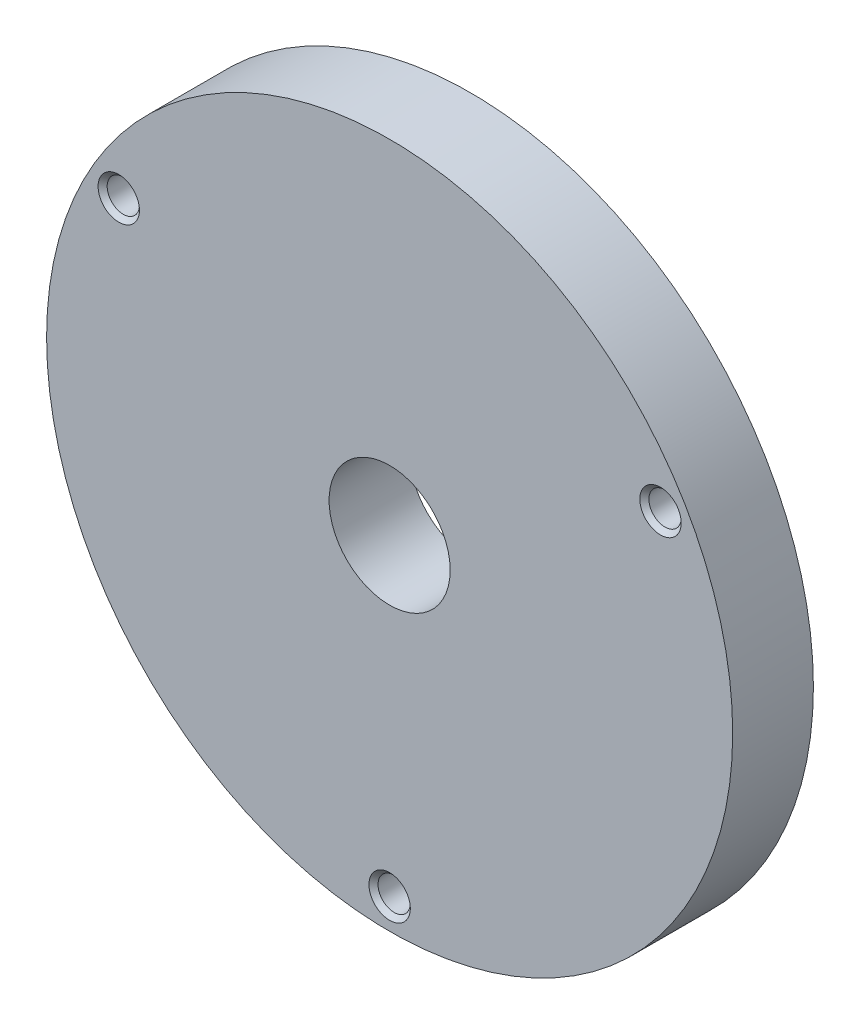
from build123d import *

# Parameters (mm, degrees)
SKETCH1_R                       = 17
BOSS_EXTRUDE1_DEPTH             = 4
M2X0_4_TAPPED_HOLE1_D           = 1.6
M2X0_4_TAPPED_HOLE1_CSINK_D     = 2.05
M2X0_4_TAPPED_HOLE1_CSINK_ANGLE = 90
CIRPATTERN1_COUNT               = 3
SKETCH4_R                       = 3
CUT_EXTRUDE1_DEPTH              = 5


with BuildPart() as part:
    # Sketch1 → Boss-Extrude1 (new body)
    with BuildSketch(Plane.XY):
        Circle(SKETCH1_R)
    extrude(amount=-BOSS_EXTRUDE1_DEPTH)

    # M2x0.4 Tapped Hole1 (through all)
    with Locations(Plane.XY):
        with Locations((0, -15.5)):
            m2x0_4_tapped_hole1 = CounterSinkHole(M2X0_4_TAPPED_HOLE1_D / 2, M2X0_4_TAPPED_HOLE1_CSINK_D / 2, counter_sink_angle=M2X0_4_TAPPED_HOLE1_CSINK_ANGLE)

    # CirPattern1: M2x0.4 Tapped Hole1 ×3 about axis
    cirpattern1_axis = Axis((0, 0, 0), (0, 0, 1))
    for i in range(1, CIRPATTERN1_COUNT):
        add(m2x0_4_tapped_hole1.rotate(cirpattern1_axis, i * 360 / CIRPATTERN1_COUNT), mode=Mode.SUBTRACT)

    # Sketch4 → Cut-Extrude1 (cut, through all)
    with BuildSketch(Plane.XY):
        Circle(SKETCH4_R)
    extrude(amount=-CUT_EXTRUDE1_DEPTH, mode=Mode.SUBTRACT)


solid = part.part
